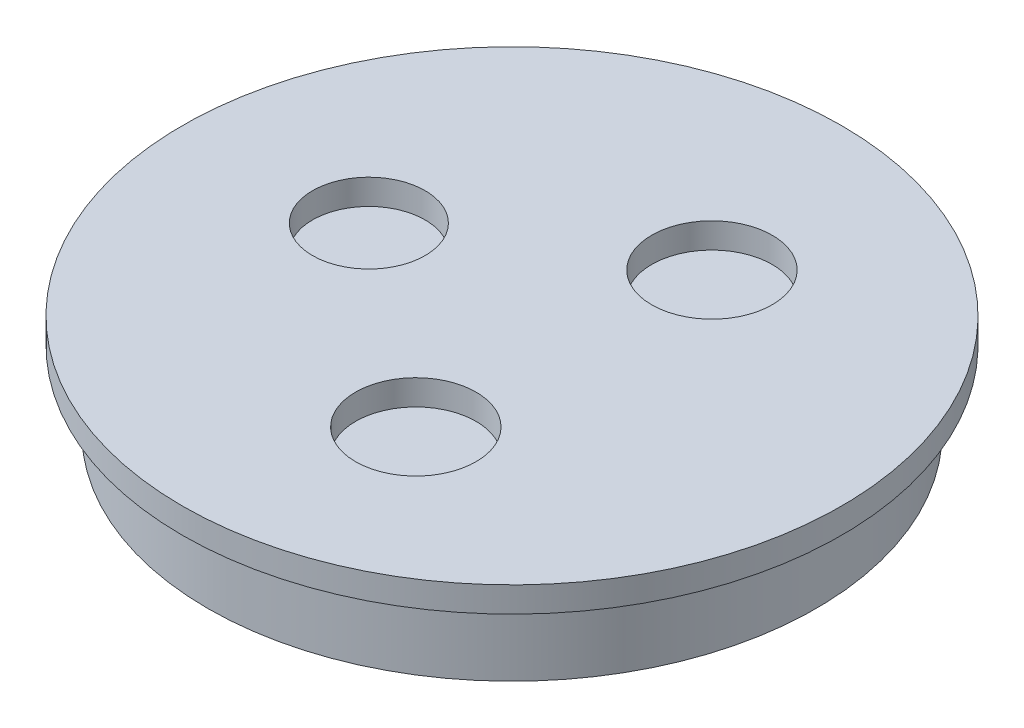
from build123d import *

# Parameters (mm, degrees)
SKETCH1_R           = 41.275
SKETCH1_R_2         = 7.05
SKETCH1_R_3         = 7.55
BOSS_EXTRUDE1_DEPTH = 3.175
SKETCH2_R           = 38.1
BOSS_EXTRUDE2_DEPTH = 9.525


with BuildPart() as part:
    # Sketch1 → Boss-Extrude1 (new body)
    with BuildSketch(Plane(origin=(0, 0, 0), x_dir=(1, 0, 0), z_dir=(0, 1, 0))):
        Circle(SKETCH1_R)
        with Locations((-19.018847828, 1.089002884)):
            Circle(SKETCH1_R_2, mode=Mode.SUBTRACT)
        with Locations((6.025718442, -18.071890251)):
            Circle(SKETCH1_R_3, mode=Mode.SUBTRACT)
        with Locations((7.550830576, 17.489638578)):
            Circle(SKETCH1_R_3, mode=Mode.SUBTRACT)
    extrude(amount=BOSS_EXTRUDE1_DEPTH)

    # Sketch2 → Boss-Extrude2 (add)
    with BuildSketch(Plane.XZ):
        Circle(SKETCH2_R)
    extrude(amount=BOSS_EXTRUDE2_DEPTH)


solid = part.part
